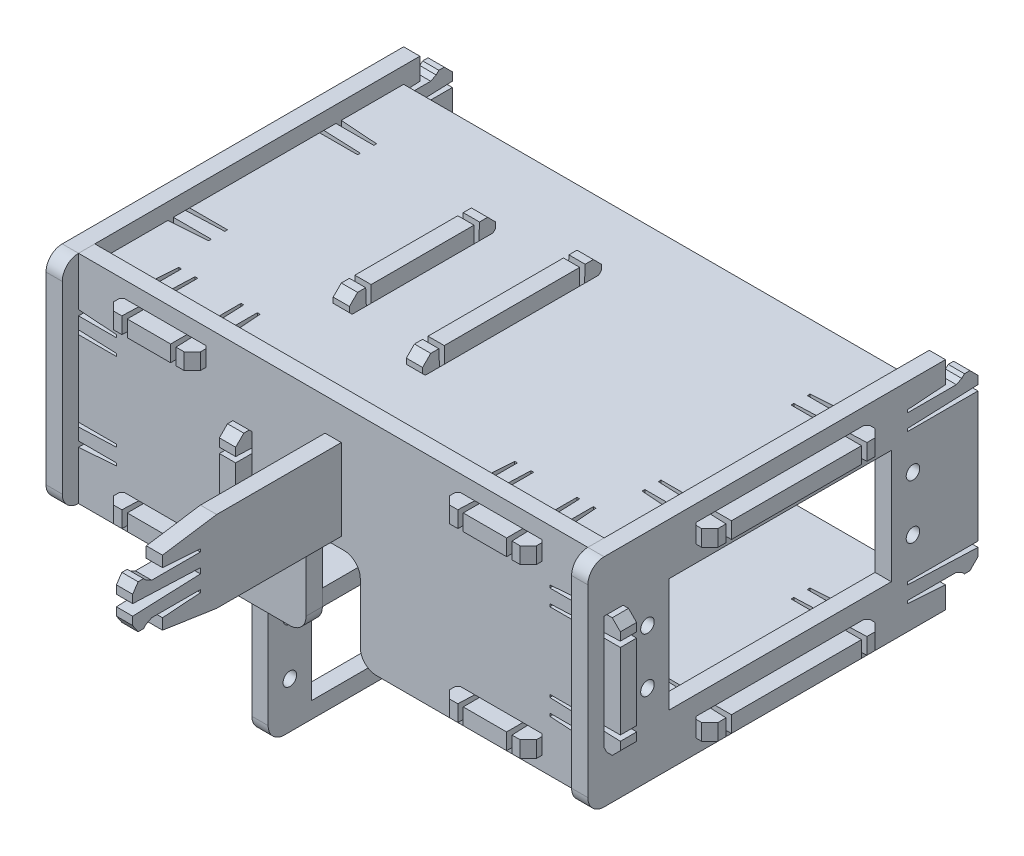
from build123d import *

# Parameters (mm, degrees)
SKETCH1_R           = 1.25
SKETCH1_W           = 3
SKETCH1_H           = 20
SKETCH1_W_2         = 30
SKETCH1_H_2         = 3
SKETCH1_W_3         = 41
SKETCH1_H_3         = 21
BOSS_EXTRUDE1_DEPTH = 3
BOSS_EXTRUDE2_DEPTH = 1.5
SKETCH3_W           = 3
SKETCH3_H           = 31
SKETCH3_H_2         = 25
BOSS_EXTRUDE3_DEPTH = 3
SKETCH4_W           = 3
SKETCH4_H           = 14
BOSS_EXTRUDE4_DEPTH = 3
SKETCH5_R           = 1.25
SKETCH5_W           = 41
SKETCH5_H           = 21
BOSS_EXTRUDE5_DEPTH = 3
SKETCH6_W           = 14
SKETCH6_H           = 3
SKETCH6_W_2         = 3
SKETCH6_H_2         = 14
SKETCH6_H_3         = 15
BOSS_EXTRUDE6_DEPTH = 3
FILLET1_R           = 3
FILLET2_R           = 3
FILLET3_R           = 3
FILLET4_R           = 3
FILLET5_R           = 3


with BuildPart() as part:
    # Sketch1 → Boss-Extrude1 (new body)
    with BuildSketch(Plane(origin=(47, 0, 0), x_dir=(0, 0, -1), z_dir=(1, 0, 0))):
        Polygon((36.5, 12), (36.5, -12), (23.5, -12), (23.5, -12.5), (36.5, -13), (36.5, -14.5), (35, -16), (34, -16), (33.5, -15.5), (32.5, -15), (23.5, -15), (23.5, -15.5), (30.5, -16), (30.5, -20), (-35.5, -20), (-35.5, 20), (30.5, 20), (30.5, 16), (23.5, 15.5), (23.5, 15), (32.5, 15), (33.5, 15.5), (34, 16), (35, 16), (36.5, 14.5), (36.5, 13), (23.5, 12.5), (23.5, 12), align=None)
        with Locations((-24.5, 5)):
            Circle(SKETCH1_R, mode=Mode.SUBTRACT)
        with Locations((-24.5, -5)):
            Circle(SKETCH1_R, mode=Mode.SUBTRACT)
        with Locations((24.5, -5)):
            Circle(SKETCH1_R, mode=Mode.SUBTRACT)
        with Locations((24.5, 5)):
            Circle(SKETCH1_R, mode=Mode.SUBTRACT)
        with Locations((-31, 0)):
            Rectangle(SKETCH1_W, SKETCH1_H, mode=Mode.SUBTRACT)
        with Locations((0, 15.5)):
            Rectangle(SKETCH1_W_2, SKETCH1_H_2, mode=Mode.SUBTRACT)
        with Locations((0, -15.5)):
            Rectangle(SKETCH1_W_2, SKETCH1_H_2, mode=Mode.SUBTRACT)
        Rectangle(SKETCH1_W_3, SKETCH1_H_3, mode=Mode.SUBTRACT)
    extrude(amount=BOSS_EXTRUDE1_DEPTH)


with BuildPart() as body_2:
    # Mirror2: mirrored copy
    add(part.part.mirror(Plane(origin=(0, 0, 0), x_dir=(0, 0, 1), z_dir=(1, 0, 0))))

    # Fillet3
    fillet3_edges = [body_2.edges().sort_by_distance(p)[0] for p in [
        (-48.5, -20, 35.5),
        (-48.5, 20, 35.5),
    ]]
    fillet(fillet3_edges, radius=FILLET3_R)


with BuildPart() as body_3:
    # Sketch2 → Boss-Extrude2 (new body, symmetric)
    with BuildSketch(Plane(origin=(0, 0, 0), x_dir=(0, 0, -1), z_dir=(1, 0, 0))):
        Polygon((-13.5, 20), (11.5, 20), (11.5, 7), (12, 7), (12.5, 20), (14, 20), (15.5, 18.5), (15.5, 17.5), (15, 17), (14.5, 16), (14.5, 7), (15, 7), (15.5, 14), (27.5, 14), (27.5, -14), (24.5, -14), (24, -7), (23.5, -7), (23.5, -16), (24, -17), (24.5, -17.5), (24.5, -18.5), (23, -20), (21.5, -20), (21, -7), (20.5, -7), (20.5, -20), (12.5, -20), (12.5, -7), (12, -7), (11.5, -20), (10, -20), (8.5, -18.5), (8.5, -17.5), (9, -17), (9.5, -16), (9.5, -7), (9, -7), (8.5, -14), (5.5, -14), (5.5, -1), (-55.5, -1), (-65.5, 0.5), (-65.5, 2.5), (-58.5, 3), (-58.5, 3.5), (-67.5, 3.5), (-68.5, 3), (-69, 2.5), (-70, 2.5), (-71, 4), (-71, 5.5), (-58.5, 6), (-58.5, 7), (-71, 7.5), (-71, 9), (-70, 10.5), (-69, 10.5), (-68.5, 10), (-67.5, 9.5), (-58.5, 9.5), (-58.5, 10), (-65.5, 10.5), (-65.5, 12.5), (-55.5, 14), (-17.5, 14), (-17, 7), (-16.5, 7), (-16.5, 16), (-17, 17), (-17.5, 17.5), (-17.5, 18.5), (-16, 20), (-14.5, 20), (-14, 7), (-13.5, 7), align=None)
    extrude(amount=BOSS_EXTRUDE2_DEPTH, both=True)


with BuildPart() as body_4:
    # Sketch3 → Boss-Extrude3 (new body)
    with BuildSketch(Plane(origin=(0, 14, 0), x_dir=(1, 0, 0), z_dir=(0, 1, 0))):
        Polygon((-53, 12), (-53, -12), (-40, -12), (-40, -12.5), (-53, -13), (-53, -14.5), (-51.5, -16), (-50.5, -16), (-50, -15.5), (-49, -15), (-40, -15), (-40, -15.5), (-47, -16), (-47, -29.5), (-39, -29.5), (-38.5, -22.5), (-38, -22.5), (-38, -31.5), (-38.5, -32.5), (-39, -33), (-39, -34), (-37.5, -35.5), (-36, -35.5), (-35.5, -22.5), (-35, -22.5), (-35, -35.5), (-27, -35.5), (-27, -22.5), (-26.5, -22.5), (-26, -35.5), (-24.5, -35.5), (-23, -34), (-23, -33), (-23.5, -32.5), (-24, -31.5), (-24, -22.5), (-23.5, -22.5), (-23, -29.5), (23, -29.5), (23.5, -22.5), (24, -22.5), (24, -31.5), (23.5, -32.5), (23, -33), (23, -34), (24.5, -35.5), (26, -35.5), (26.5, -22.5), (27, -22.5), (27, -35.5), (35, -35.5), (35, -22.5), (35.5, -22.5), (36, -35.5), (37.5, -35.5), (39, -34), (39, -33), (38.5, -32.5), (38, -31.5), (38, -22.5), (38.5, -22.5), (39, -29.5), (47, -29.5), (47, -16), (40, -15.5), (40, -15), (49, -15), (50, -15.5), (50.5, -16), (51.5, -16), (53, -14.5), (53, -13), (40, -12.5), (40, -12), (53, -12), (53, 12), (40, 12), (40, 12.5), (53, 13), (53, 14.5), (51.5, 16), (50.5, 16), (50, 15.5), (49, 15), (40, 15), (40, 15.5), (47, 16), (47, 27.5), (-47, 27.5), (-47, 16), (-40, 15.5), (-40, 15), (-49, 15), (-50, 15.5), (-50.5, 16), (-51.5, 16), (-53, 14.5), (-53, 13), (-40, 12.5), (-40, 12), align=None)
        with Locations((0, -1)):
            Rectangle(SKETCH3_W, SKETCH3_H, mode=Mode.SUBTRACT)
        with Locations((-16.5, -1)):
            Rectangle(SKETCH3_W, SKETCH3_H_2, mode=Mode.SUBTRACT)
    extrude(amount=BOSS_EXTRUDE3_DEPTH)


with BuildPart() as body_5:
    # Sketch4 → Boss-Extrude4 (new body)
    with BuildSketch(Plane(origin=(0, -17, 0), x_dir=(1, 0, 0), z_dir=(0, 1, 0))):
        Polygon((-53, -12), (-53, 12), (-40, 12), (-40, 12.5), (-53, 13), (-53, 14.5), (-51.5, 16), (-50.5, 16), (-50, 15.5), (-49, 15), (-40, 15), (-40, 15.5), (-47, 16), (-47, 27.5), (47, 27.5), (47, 16), (40, 15.5), (40, 15), (49, 15), (50, 15.5), (50.5, 16), (51.5, 16), (53, 14.5), (53, 13), (40, 12.5), (40, 12), (53, 12), (53, -12), (40, -12), (40, -12.5), (53, -13), (53, -14.5), (51.5, -16), (50.5, -16), (50, -15.5), (49, -15), (40, -15), (40, -15.5), (47, -16), (47, -29.5), (39, -29.5), (38.5, -22.5), (38, -22.5), (38, -31.5), (38.5, -32.5), (39, -33), (39, -34), (37.5, -35.5), (36, -35.5), (35.5, -22.5), (35, -22.5), (35, -35.5), (27, -35.5), (27, -22.5), (26.5, -22.5), (26, -35.5), (24.5, -35.5), (23, -34), (23, -33), (23.5, -32.5), (24, -31.5), (24, -22.5), (23.5, -22.5), (23, -29.5), (5, -29.5), (5, 5.5), (-5, 5.5), (-5, -29.5), (-15, -29.5), (-15, 7.5), (-18, 7.5), (-18, -29.5), (-23, -29.5), (-23.5, -22.5), (-24, -22.5), (-24, -31.5), (-23.5, -32.5), (-23, -33), (-23, -34), (-24.5, -35.5), (-26, -35.5), (-26.5, -22.5), (-27, -22.5), (-27, -35.5), (-35, -35.5), (-35, -22.5), (-35.5, -22.5), (-36, -35.5), (-37.5, -35.5), (-39, -34), (-39, -33), (-38.5, -32.5), (-38, -31.5), (-38, -22.5), (-38.5, -22.5), (-39, -29.5), (-47, -29.5), (-47, -16), (-40, -15.5), (-40, -15), (-49, -15), (-50, -15.5), (-50.5, -16), (-51.5, -16), (-53, -14.5), (-53, -13), (-40, -12.5), (-40, -12), align=None)
        with Locations((0, 16.5)):
            Rectangle(SKETCH4_W, SKETCH4_H, mode=Mode.SUBTRACT)
    extrude(amount=BOSS_EXTRUDE4_DEPTH)

    # Fillet5
    fillet5_edges = [body_5.edges().sort_by_distance(p)[0] for p in [
        (5, -15.5, -5.5),
        (-5, -15.5, -5.5),
    ]]
    fillet(fillet5_edges, radius=FILLET5_R)


with BuildPart() as body_6:
    # Sketch5 → Boss-Extrude5 (new body)
    with BuildSketch(Plane(origin=(-18, 0, 0), x_dir=(0, 0, -1), z_dir=(1, 0, 0))):
        Polygon((7.5, -14), (27.5, -14), (27.5, 14), (12.5, 14), (12, 7), (11.5, 7), (11.5, 16), (12, 17), (12.5, 17.5), (12.5, 18.5), (11, 20), (9.5, 20), (9, 7), (8.5, 7), (8.5, 20), (-10.5, 20), (-10.5, 7), (-11, 7), (-11.5, 20), (-13, 20), (-14.5, 18.5), (-14.5, 17.5), (-14, 17), (-13.5, 16), (-13.5, 7), (-14, 7), (-14.5, 14), (-29.5, 14), (-29.5, 8), (-22.5, 7.5), (-22.5, 7), (-31.5, 7), (-32.5, 7.5), (-33, 8), (-34, 8), (-35.5, 6.5), (-35.5, 5), (-22.5, 4.5), (-22.5, 4), (-35.5, 4), (-35.5, -4), (-22.5, -4), (-22.5, -4.5), (-35.5, -5), (-35.5, -6.5), (-34, -8), (-33, -8), (-32.5, -7.5), (-31.5, -7), (-22.5, -7), (-22.5, -7.5), (-29.5, -8), (-29.5, -44), (27.5, -44), (27.5, -17), (7.5, -17), align=None)
        with Locations((-25.5, -25.5)):
            Circle(SKETCH5_R, mode=Mode.SUBTRACT)
        with Locations((-25.5, -35.5)):
            Circle(SKETCH5_R, mode=Mode.SUBTRACT)
        with Locations((23.5, -35.5)):
            Circle(SKETCH5_R, mode=Mode.SUBTRACT)
        with Locations((23.5, -25.5)):
            Circle(SKETCH5_R, mode=Mode.SUBTRACT)
        with Locations((-1, -30.5)):
            Rectangle(SKETCH5_W, SKETCH5_H, mode=Mode.SUBTRACT)
    extrude(amount=BOSS_EXTRUDE5_DEPTH)

    # Fillet1
    fillet1_edges = [body_6.edges().sort_by_distance(p)[0] for p in [
        (-16.5, -44, -27.5),
        (-16.5, -44, 29.5),
    ]]
    fillet(fillet1_edges, radius=FILLET1_R)


with BuildPart() as body_7:
    # Sketch6 → Boss-Extrude6 (new body)
    with BuildSketch(Plane.XY.offset(29.5)):
        Polygon((-53, -7), (-53, 7), (-40, 7), (-40, 7.5), (-53, 8), (-53, 9.5), (-51.5, 11), (-50.5, 11), (-50, 10.5), (-49, 10), (-40, 10), (-40, 10.5), (-47, 11), (-47, 20), (47, 20), (47, 11), (40, 10.5), (40, 10), (49, 10), (50, 10.5), (50.5, 11), (51.5, 11), (53, 9.5), (53, 8), (40, 7.5), (40, 7), (53, 7), (53, -7), (40, -7), (40, -7.5), (53, -8), (53, -9.5), (51.5, -11), (50.5, -11), (50, -10.5), (49, -10), (40, -10), (40, -10.5), (47, -11), (47, -20), (5, -20), (5, -3), (-5, -3), (-5, -20), (-47, -20), (-47, -11), (-40, -10.5), (-40, -10), (-49, -10), (-50, -10.5), (-50.5, -11), (-51.5, -11), (-53, -9.5), (-53, -8), (-40, -7.5), (-40, -7), align=None)
        with Locations((-31, -15.5)):
            Rectangle(SKETCH6_W, SKETCH6_H, mode=Mode.SUBTRACT)
        with Locations((31, -15.5)):
            Rectangle(SKETCH6_W, SKETCH6_H, mode=Mode.SUBTRACT)
        with Locations((-31, 15.5)):
            Rectangle(SKETCH6_W, SKETCH6_H, mode=Mode.SUBTRACT)
        with Locations((31, 15.5)):
            Rectangle(SKETCH6_W, SKETCH6_H, mode=Mode.SUBTRACT)
        with Locations((-16.5, 0)):
            Rectangle(SKETCH6_W_2, SKETCH6_H_2, mode=Mode.SUBTRACT)
        with Locations((0, 6.5)):
            Rectangle(SKETCH6_W_2, SKETCH6_H_3, mode=Mode.SUBTRACT)
    extrude(amount=BOSS_EXTRUDE6_DEPTH)

    # Fillet2
    fillet2_edges = [body_7.edges().sort_by_distance(p)[0] for p in [
        (5, -20, 31),
        (5, -3, 31),
        (-5, -3, 31),
        (-5, -20, 31),
    ]]
    fillet(fillet2_edges, radius=FILLET2_R)


with BuildPart() as part_1:
    add(part.part)

    # Fillet4
    fillet4_edges = [part_1.edges().sort_by_distance(p)[0] for p in [
        (48.5, -20, 35.5),
        (48.5, 20, 35.5),
    ]]
    fillet(fillet4_edges, radius=FILLET4_R)


solid = Compound([body_2.part, body_3.part, body_4.part, body_5.part, body_6.part, body_7.part, part_1.part])
